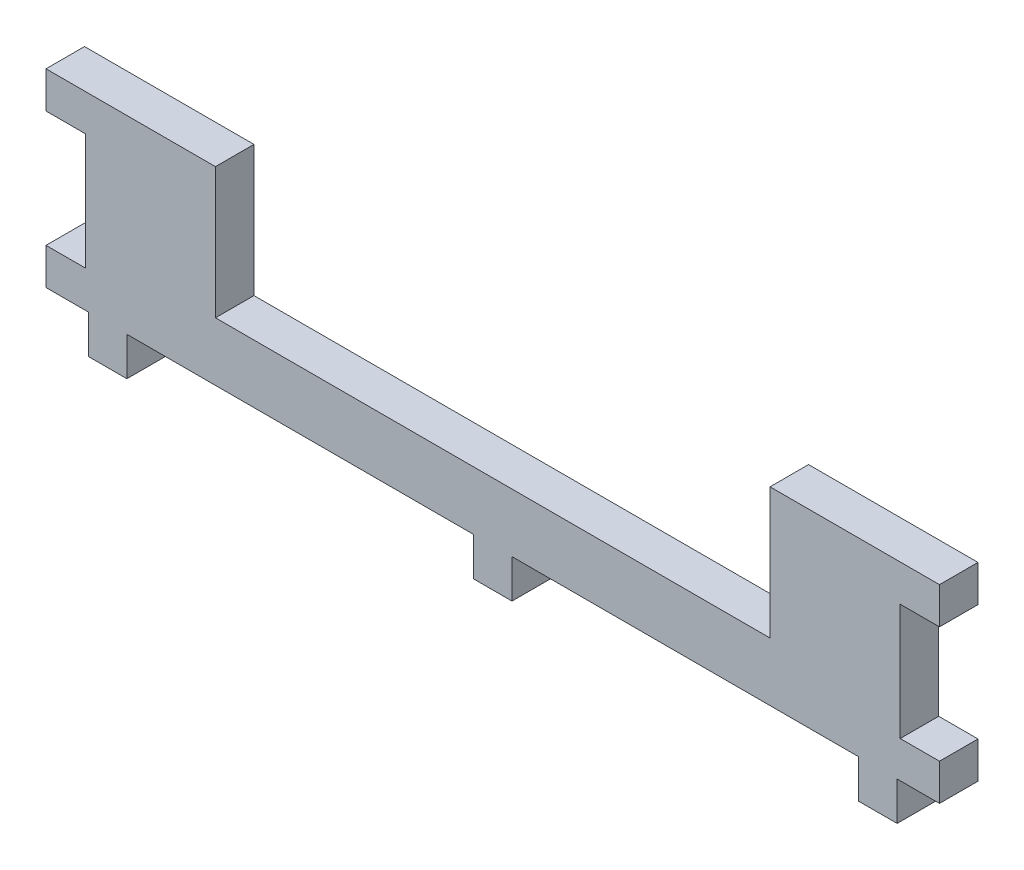
from build123d import *

# Parameters (mm, degrees)
SKETCH1_W           = 116
SKETCH1_H           = 12.3
BOSS_EXTRUDE1_DEPTH = 5
SKETCH2_W           = 5
SKETCH2_H           = 5
BOSS_EXTRUDE2_DEPTH = 5
SKETCH3_W           = 72
SKETCH3_H           = 5
CUT_EXTRUDE1_DEPTH  = 17
SKETCH4_W           = 5
SKETCH4_H           = 5
BOSS_EXTRUDE3_DEPTH = 5
SKETCH5_W           = 5
SKETCH5_H           = 15.1
CUT_EXTRUDE2_DEPTH  = 5.1


with BuildPart() as part:
    # Sketch1 → Boss-Extrude1 (new body)
    with BuildSketch(Plane.XY):
        Rectangle(SKETCH1_W, SKETCH1_H)
    extrude(amount=BOSS_EXTRUDE1_DEPTH)

    # Mirror1: part across plane


with BuildPart() as part_1:
    add(part.part)
    add(part.part.mirror(Plane(origin=(-58, 6.15, 5), x_dir=(0, 0, 1), z_dir=(0, -1, 0))))

    # Sketch2 → Boss-Extrude2 (add)
    with BuildSketch(Plane.XZ.offset(6.15)):
        with Locations((-50, 2.5)):
            Rectangle(SKETCH2_W, SKETCH2_H)
        with Locations((50, 2.5)):
            Rectangle(SKETCH2_W, SKETCH2_H)
    extrude(amount=BOSS_EXTRUDE2_DEPTH)

    # Sketch3 → Cut-Extrude1 (cut)
    with BuildSketch(Plane(origin=(0, 18.45, 0), x_dir=(1, 0, 0), z_dir=(0, 1, 0))):
        with Locations((0, -2.5)):
            Rectangle(SKETCH3_W, SKETCH3_H)
    extrude(amount=-CUT_EXTRUDE1_DEPTH, mode=Mode.SUBTRACT)

    # Sketch4 → Boss-Extrude3 (add)
    with BuildSketch(Plane.XZ.offset(6.15)):
        with Locations((0, 2.5)):
            Rectangle(SKETCH4_W, SKETCH4_H)
    extrude(amount=BOSS_EXTRUDE3_DEPTH)

    # Sketch5 → Cut-Extrude2 (cut)
    with BuildSketch(Plane.ZY.offset(58)):
        with Locations((2.5, 6.15)):
            Rectangle(SKETCH5_W, SKETCH5_H)
    cut_extrude2 = extrude(amount=-CUT_EXTRUDE2_DEPTH, mode=Mode.SUBTRACT)

    # Mirror2: Cut-Extrude2 across plane
    add(cut_extrude2.mirror(Plane(origin=(0, 0, 0), x_dir=(0, 0, 1), z_dir=(1, 0, 0))), mode=Mode.SUBTRACT)


solid = part_1.part
